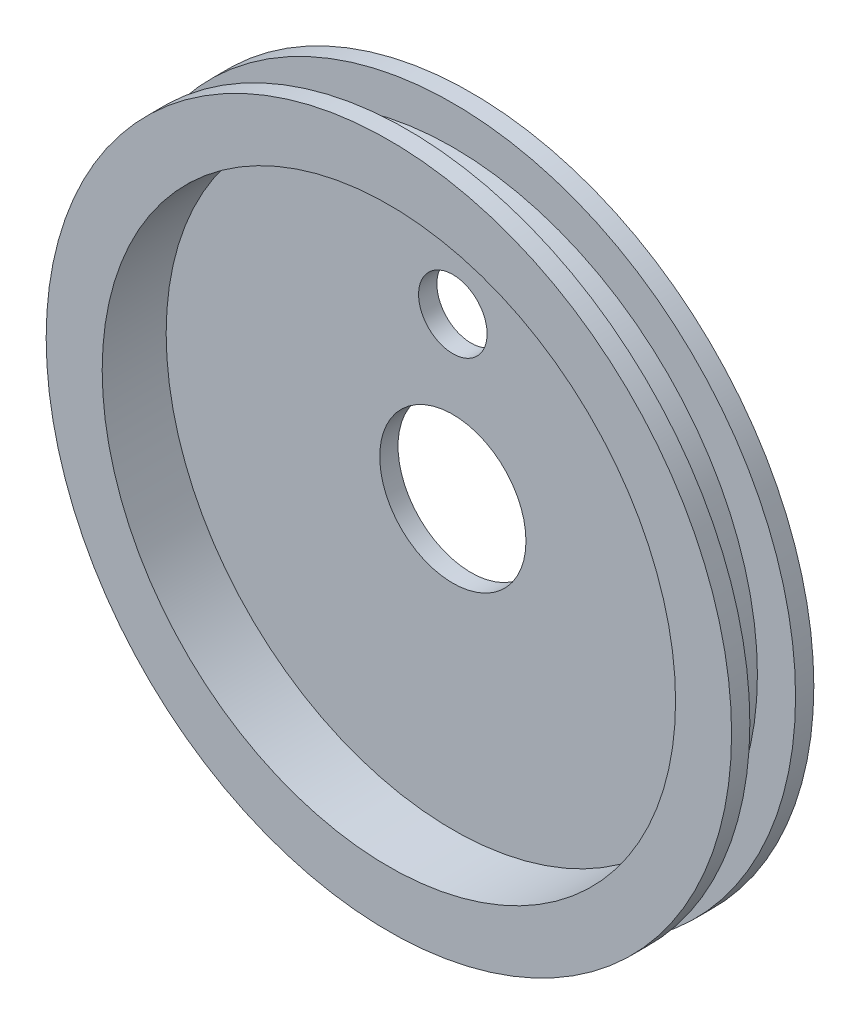
from build123d import *

# Parameters (mm, degrees)
SKETCH3_R           = 10.16
CUT_EXTRUDE1_DEPTH  = 2.54
SKETCH5_R           = 4.7625
CUT_EXTRUDE2_DEPTH  = 6.35
SKETCH11_R          = 0.889
CUT_EXTRUDE6_DEPTH  = 55.372
SKETCH12_R          = 28.194
SKETCH12_R_2        = 26.924
BOSS_EXTRUDE1_DEPTH = 2.54


with BuildPart() as part:
    # Sketch2 → Revolve1 (revolve)
    with BuildSketch(Plane(origin=(0, 0, 0), x_dir=(0, 0, -1), z_dir=(1, 0, 0))):
        Polygon((-6.35, 42.32529), (0, 42.32529), (0, 47.625), (2.54, 47.625), (2.54, 0), (0, 0), (0, 39.839805153), (-8.89, 39.839805153), (-8.89, 47.625), (-6.35, 47.625), align=None)
    revolve(axis=Axis((0, 0, 0), (0, 0, -1)))

    # Sketch3 → Cut-Extrude1 (cut)
    with BuildSketch(Plane.XY):
        Circle(SKETCH3_R)
    extrude(amount=-CUT_EXTRUDE1_DEPTH, mode=Mode.SUBTRACT)

    # Sketch5 → Cut-Extrude2 (cut)
    with BuildSketch(Plane.XY):
        with Locations((0, 22.225)):
            Circle(SKETCH5_R)
    extrude(amount=-CUT_EXTRUDE2_DEPTH, mode=Mode.SUBTRACT)

    # Sketch11 → Cut-Extrude6 (cut)
    with BuildSketch(Plane(origin=(0, 0, 0), x_dir=(1, 0, 0), z_dir=(0, 1, 0))):
        with Locations((0, -3.870418615)):
            Circle(SKETCH11_R)
    extrude(amount=CUT_EXTRUDE6_DEPTH, mode=Mode.SUBTRACT)

    # Sketch12 → Boss-Extrude1 (add)
    with BuildSketch(Plane(origin=(0, 0, -2.54), x_dir=(-1, 0, 0), z_dir=(0, 0, -1))):
        Circle(SKETCH12_R)
        Circle(SKETCH12_R_2, mode=Mode.SUBTRACT)
    extrude(amount=BOSS_EXTRUDE1_DEPTH)


solid = part.part
